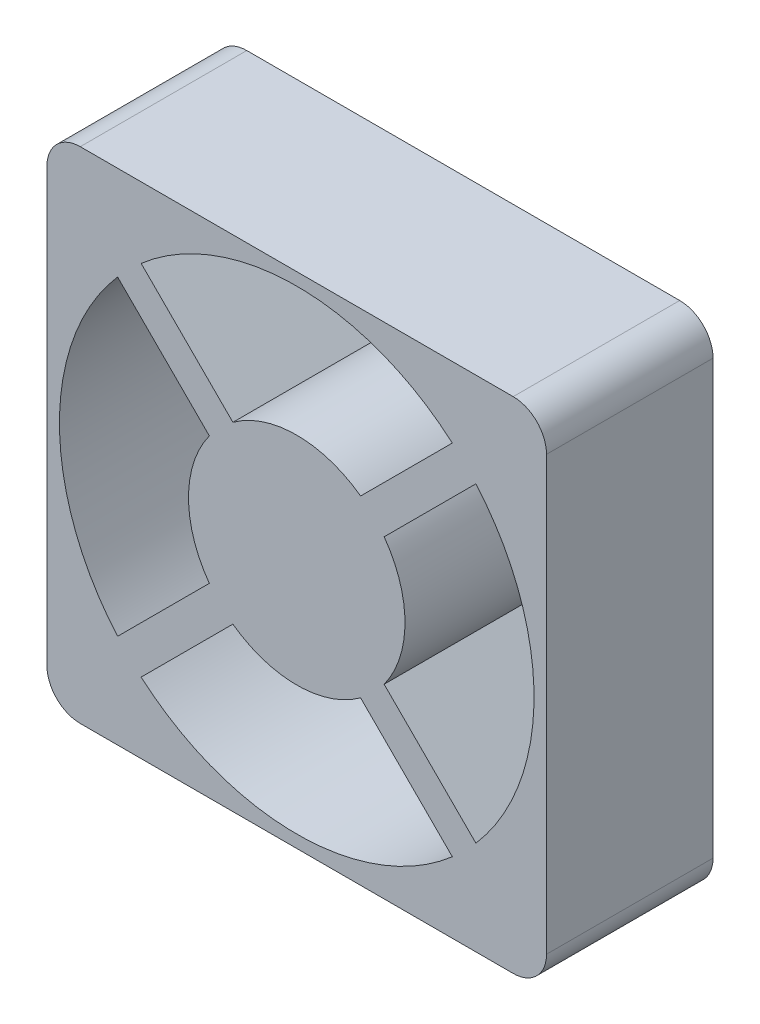
from build123d import *

# Parameters (mm, degrees)
BOSS_EXTRUDE1_DEPTH = 10
FILLET1_R           = 2


with BuildPart() as part:
    # Sketch1 → Boss-Extrude1 (new body)
    with BuildSketch(Plane.XY):
        with BuildLine():
            ThreePointArc((-10.758537028, -9.344323465), (-14.25, 0), (-10.758537028, 9.344323465))
            Line((-10.758537028, 9.344323465), (-15, 13.585786438))
            Line((-15, 13.585786438), (-15, -13.585786438))
            Line((-15, -13.585786438), (-10.758537028, -9.344323465))
        make_face()
        with BuildLine():
            ThreePointArc((-9.344323465, -10.758537028), (-10.076271632, -10.076271632), (-10.758537028, -9.344323465))
            Line((-10.758537028, -9.344323465), (-15, -13.585786438))
            Line((-15, -13.585786438), (-15, -15))
            Line((-15, -15), (-13.585786438, -15))
            Line((-13.585786438, -15), (-9.344323465, -10.758537028))
        make_face()
        with BuildLine():
            ThreePointArc((9.344323465, -10.758537028), (0, -14.25), (-9.344323465, -10.758537028))
            Line((-9.344323465, -10.758537028), (-13.585786438, -15))
            Line((-13.585786438, -15), (13.585786438, -15))
            Line((13.585786438, -15), (9.344323465, -10.758537028))
        make_face()
        with BuildLine():
            Line((15, -15), (15, -13.585786438))
            Line((15, -13.585786438), (10.758537028, -9.344323465))
            ThreePointArc((10.758537028, -9.344323465), (10.076271632, -10.076271632), (9.344323465, -10.758537028))
            Line((9.344323465, -10.758537028), (13.585786438, -15))
            Line((13.585786438, -15), (15, -15))
        make_face()
        with BuildLine():
            Line((15, 13.585786438), (10.758537028, 9.344323465))
            ThreePointArc((10.758537028, 9.344323465), (13.348626383, 4.987652121), (14.25, 0))
            ThreePointArc((14.25, 0), (13.348626383, -4.987652121), (10.758537028, -9.344323465))
            Line((10.758537028, -9.344323465), (15, -13.585786438))
            Line((15, -13.585786438), (15, 13.585786438))
        make_face()
        with BuildLine():
            Line((15, 15), (13.585786438, 15))
            Line((13.585786438, 15), (9.344323465, 10.758537028))
            ThreePointArc((9.344323465, 10.758537028), (10.076271632, 10.076271632), (10.758537028, 9.344323465))
            Line((10.758537028, 9.344323465), (15, 13.585786438))
            Line((15, 13.585786438), (15, 15))
        make_face()
        with BuildLine():
            Line((13.585786438, 15), (-13.585786438, 15))
            Line((-13.585786438, 15), (-9.344323465, 10.758537028))
            ThreePointArc((-9.344323465, 10.758537028), (0, 14.25), (9.344323465, 10.758537028))
            Line((9.344323465, 10.758537028), (13.585786438, 15))
        make_face()
        with BuildLine():
            Line((-9.344323465, 10.758537028), (-13.585786438, 15))
            Line((-13.585786438, 15), (-15, 15))
            Line((-15, 15), (-15, 13.585786438))
            Line((-15, 13.585786438), (-10.758537028, 9.344323465))
            ThreePointArc((-10.758537028, 9.344323465), (-10.076271632, 10.076271632), (-9.344323465, 10.758537028))
        make_face()
        with BuildLine():
            Line((3.83436875, -5.248582312), (0, -1.414213562))
            Line((0, -1.414213562), (-3.83436875, -5.248582312))
            ThreePointArc((-3.83436875, -5.248582312), (0, -6.5), (3.83436875, -5.248582312))
        make_face()
        with BuildLine():
            Line((0, -1.414213562), (-1.414213562, 0))
            Line((-1.414213562, 0), (-5.248582312, -3.83436875))
            ThreePointArc((-5.248582312, -3.83436875), (-4.596194078, -4.596194078), (-3.83436875, -5.248582312))
            Line((-3.83436875, -5.248582312), (0, -1.414213562))
        make_face()
        with BuildLine():
            Line((-1.414213562, 0), (-5.248582312, 3.83436875))
            ThreePointArc((-5.248582312, 3.83436875), (-6.5, 0), (-5.248582312, -3.83436875))
            Line((-5.248582312, -3.83436875), (-1.414213562, 0))
        make_face()
        with BuildLine():
            Line((0, 1.414213562), (-3.83436875, 5.248582312))
            ThreePointArc((-3.83436875, 5.248582312), (-4.596194078, 4.596194078), (-5.248582312, 3.83436875))
            Line((-5.248582312, 3.83436875), (-1.414213562, 0))
            Line((-1.414213562, 0), (0, 1.414213562))
        make_face()
        with BuildLine():
            ThreePointArc((3.83436875, 5.248582312), (0, 6.5), (-3.83436875, 5.248582312))
            Line((-3.83436875, 5.248582312), (0, 1.414213562))
            Line((0, 1.414213562), (3.83436875, 5.248582312))
        make_face()
        with BuildLine():
            Line((3.83436875, 5.248582312), (0, 1.414213562))
            Line((0, 1.414213562), (1.414213562, 0))
            Line((1.414213562, 0), (5.248582312, 3.83436875))
            ThreePointArc((5.248582312, 3.83436875), (4.596194078, 4.596194078), (3.83436875, 5.248582312))
        make_face()
        with BuildLine():
            Line((5.248582312, 3.83436875), (1.414213562, 0))
            Line((1.414213562, 0), (5.248582312, -3.83436875))
            ThreePointArc((5.248582312, -3.83436875), (6.179230738, -2.01670709), (6.5, 0))
            ThreePointArc((6.5, 0), (6.179230738, 2.01670709), (5.248582312, 3.83436875))
        make_face()
        with BuildLine():
            Line((5.248582312, -3.83436875), (1.414213562, 0))
            Line((1.414213562, 0), (0, -1.414213562))
            Line((0, -1.414213562), (3.83436875, -5.248582312))
            ThreePointArc((3.83436875, -5.248582312), (4.596194078, -4.596194078), (5.248582312, -3.83436875))
        make_face()
        with BuildLine():
            Line((-3.83436875, 5.248582312), (-9.344323465, 10.758537028))
            ThreePointArc((-9.344323465, 10.758537028), (-10.076271632, 10.076271632), (-10.758537028, 9.344323465))
            Line((-10.758537028, 9.344323465), (-5.248582312, 3.83436875))
            ThreePointArc((-5.248582312, 3.83436875), (-4.596194078, 4.596194078), (-3.83436875, 5.248582312))
        make_face()
        with BuildLine():
            Line((10.758537028, -9.344323465), (5.248582312, -3.83436875))
            ThreePointArc((5.248582312, -3.83436875), (4.596194078, -4.596194078), (3.83436875, -5.248582312))
            Line((3.83436875, -5.248582312), (9.344323465, -10.758537028))
            ThreePointArc((9.344323465, -10.758537028), (10.076271632, -10.076271632), (10.758537028, -9.344323465))
        make_face()
        with BuildLine():
            ThreePointArc((10.758537028, 9.344323465), (10.076271632, 10.076271632), (9.344323465, 10.758537028))
            Line((9.344323465, 10.758537028), (3.83436875, 5.248582312))
            ThreePointArc((3.83436875, 5.248582312), (4.596194078, 4.596194078), (5.248582312, 3.83436875))
            Line((5.248582312, 3.83436875), (10.758537028, 9.344323465))
        make_face()
        with BuildLine():
            Line((-5.248582312, -3.83436875), (-10.758537028, -9.344323465))
            ThreePointArc((-10.758537028, -9.344323465), (-10.076271632, -10.076271632), (-9.344323465, -10.758537028))
            Line((-9.344323465, -10.758537028), (-3.83436875, -5.248582312))
            ThreePointArc((-3.83436875, -5.248582312), (-4.596194078, -4.596194078), (-5.248582312, -3.83436875))
        make_face()
        Polygon((1.414213562, 0), (0, 1.414213562), (-1.414213562, 0), (0, -1.414213562), align=None)
    extrude(amount=BOSS_EXTRUDE1_DEPTH)

    # Fillet1
    fillet1_edges = [part.edges().sort_by_distance(p)[0] for p in [
        (15, -15, 5),
        (-15, -15, 5),
        (-15, 15, 5),
        (15, 15, 5),
    ]]
    fillet(fillet1_edges, radius=FILLET1_R)


solid = part.part
